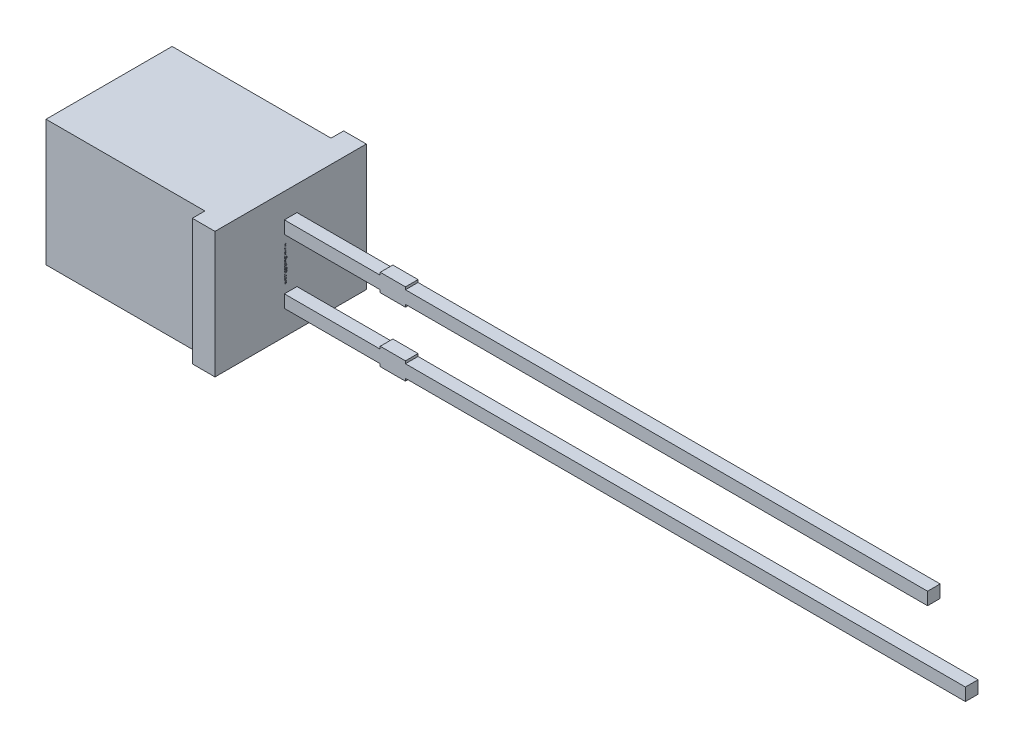
from build123d import *

# Parameters (mm, degrees)
SKETCH1_W          = 7.2
SKETCH1_H          = 5
EXTRUDE1_DEPTH     = 2.5
SKETCH1_4_W        = 3.8
SKETCH1_4_H        = 0.5
SKETCH1_4_W_2      = 1
SKETCH1_4_W_3      = 20.7
SKETCH1_4_H_2      = 0.1
SKETCH1_4_W_4      = 22.2
EXTRUDE2_DEPTH     = 0.25
EXTRUDE3_DEPTH     = 3
SKETCH2_W          = 0.026582278
SKETCH2_H          = 0.025316456
CUT_EXTRUDE1_DEPTH = 0.01


with BuildPart() as part:
    # Sketch1 → Extrude1 (new body, symmetric)
    with BuildSketch(Plane.XY):
        Rectangle(SKETCH1_W, SKETCH1_H)
    extrude(amount=EXTRUDE1_DEPTH, both=True)

    # Sketch1_4 → Extrude2 (add, symmetric)
    with BuildSketch(Plane.XY):
        with Locations((5.5, 1.27)):
            Rectangle(SKETCH1_4_W, SKETCH1_4_H)
        with Locations((7.9, 1.27)):
            Rectangle(SKETCH1_4_W_2, SKETCH1_4_H)
        with Locations((18.75, 1.27)):
            Rectangle(SKETCH1_4_W_3, SKETCH1_4_H)
        with Locations((7.9, 1.57)):
            Rectangle(SKETCH1_4_W_2, SKETCH1_4_H_2)
        with Locations((7.9, 0.97)):
            Rectangle(SKETCH1_4_W_2, SKETCH1_4_H_2)
        with Locations((7.9, -1.27)):
            Rectangle(SKETCH1_4_W_2, SKETCH1_4_H)
        with Locations((7.9, -0.97)):
            Rectangle(SKETCH1_4_W_2, SKETCH1_4_H_2)
        with Locations((19.5, -1.27)):
            Rectangle(SKETCH1_4_W_4, SKETCH1_4_H)
        with Locations((5.5, -1.27)):
            Rectangle(SKETCH1_4_W, SKETCH1_4_H)
        with Locations((7.9, -1.57)):
            Rectangle(SKETCH1_4_W_2, SKETCH1_4_H_2)
    extrude(amount=EXTRUDE2_DEPTH, both=True)

    # Sketch1_5 → Extrude3 (add, symmetric)
    with BuildSketch(Plane.XY):
        Polygon((2.7, 2.5), (2.7, -2.5), (3.6, -2.5), (3.6, -1.52), (3.6, -1.02), (3.6, 1.02), (3.6, 1.52), (3.6, 2.5), align=None)
    extrude(amount=EXTRUDE3_DEPTH, both=True)

    # Sketch2 → Cut-Extrude1 (cut)
    with BuildSketch(Plane(origin=(3.6, 0, 0), x_dir=(0, 0, -1), z_dir=(1, 0, 0))):
        Polygon((-0.175316456, 0.572151899), (-0.25, 0.595609177), (-0.25, 0.620352057), (-0.199663766, 0.636768196), (-0.25, 0.652294304), (-0.25, 0.678026108), (-0.175316456, 0.701265823), (-0.175316456, 0.676087816), (-0.226799842, 0.663093354), (-0.175316456, 0.646677215), (-0.175316456, 0.625178006), (-0.226799842, 0.608860759), (-0.175316456, 0.596044304), align=None)
        Polygon((-0.175316456, 0.437974684), (-0.25, 0.461431962), (-0.25, 0.486174842), (-0.199663766, 0.502590981), (-0.25, 0.518117089), (-0.25, 0.543848892), (-0.175316456, 0.567088608), (-0.175316456, 0.541910601), (-0.226799842, 0.528916139), (-0.175316456, 0.5125), (-0.175316456, 0.491000791), (-0.226799842, 0.474683544), (-0.175316456, 0.461867089), align=None)
        Polygon((-0.175316456, 0.303797468), (-0.25, 0.327254747), (-0.25, 0.351997627), (-0.199663766, 0.368413766), (-0.25, 0.383939873), (-0.25, 0.409671677), (-0.175316456, 0.432911392), (-0.175316456, 0.407733386), (-0.226799842, 0.394738924), (-0.175316456, 0.378322785), (-0.175316456, 0.356823576), (-0.226799842, 0.340506329), (-0.175316456, 0.327689873), align=None)
        with Locations((-0.236708861, 0.275949367)):
            Rectangle(SKETCH2_W, SKETCH2_H)
        with BuildLine():
            add(Edge.make_bspline(
                [(-0.218829114, 0.159493671), (-0.220051248, 0.159530169), (-0.22245111, 0.15960184), (-0.225958798, 0.160211426), (-0.229283102, 0.161205393), (-0.232447248, 0.162577732), (-0.235416736, 0.164371189), (-0.238219628, 0.16655446), (-0.240824172, 0.169143343), (-0.243260547, 0.172090146), (-0.245442658, 0.175387089), (-0.247348691, 0.178984804), (-0.248943362, 0.18286483), (-0.250282428, 0.187013042), (-0.251270861, 0.191459588), (-0.251994849, 0.196177087), (-0.252468166, 0.201170514), (-0.252510134, 0.204594091), (-0.252531646, 0.206348892)],
                knots=[0, 0, 0, 0, 0.907312236, 1.78165839, 2.635367075, 3.479697475, 4.336364812, 5.205276731, 6.11257575, 7.058770404, 8.040786331, 9.044147278, 10.078219212, 11.153049307, 12.278104542, 13.457648573, 14.696882856, 16, 16, 16, 16], degree=3))
            add(Edge.make_bspline(
                [(-0.252531646, 0.206348892), (-0.252507574, 0.208367148), (-0.252460949, 0.21227633), (-0.25203235, 0.217939855), (-0.251386211, 0.223207892), (-0.250419669, 0.228103607), (-0.249218904, 0.232708206), (-0.247927612, 0.237141474), (-0.246463197, 0.241422786), (-0.245363039, 0.244195876), (-0.244818038, 0.24556962)],
                knots=[0, 0, 0, 0, 1.203215828, 2.33052265, 3.384689099, 4.366106119, 5.303329643, 6.221311756, 7.118865988, 8, 8, 8, 8], degree=3))
            Line((-0.244818038, 0.24556962), (-0.220886076, 0.24556962))
            Line((-0.220886076, 0.24556962), (-0.220886076, 0.242721519))
            add(Edge.make_bspline(
                [(-0.220886076, 0.242721519), (-0.221967531, 0.241356205), (-0.224124092, 0.238633592), (-0.226886697, 0.234200359), (-0.22928886, 0.229552713), (-0.231262862, 0.224707243), (-0.232849186, 0.219810398), (-0.233942713, 0.21493502), (-0.234690062, 0.210169433), (-0.234770569, 0.207010864), (-0.234810127, 0.205458861)],
                knots=[0, 0, 0, 0, 1.030622468, 2.055194264, 3.087043286, 4.125157485, 5.149848264, 6.130935704, 7.081611712, 8, 8, 8, 8], degree=3))
            add(Edge.make_bspline(
                [(-0.234810127, 0.205458861), (-0.234809232, 0.205030082), (-0.234807317, 0.2041121), (-0.234678474, 0.202644063), (-0.234585311, 0.200985464), (-0.234376093, 0.199206598), (-0.23415751, 0.197415781), (-0.23377719, 0.195761121), (-0.233415351, 0.194257482), (-0.233047173, 0.193351), (-0.232871835, 0.192919304)],
                knots=[0, 0, 0, 0, 0.806378557, 1.726393851, 2.771014456, 3.931269413, 5.096090628, 6.161710732, 7.124547685, 8, 8, 8, 8], degree=3))
            add(Edge.make_bspline(
                [(-0.232871835, 0.192919304), (-0.232644012, 0.192439517), (-0.23219629, 0.191496634), (-0.231378683, 0.190201714), (-0.230507381, 0.189019042), (-0.229541962, 0.187957582), (-0.228364053, 0.187107314), (-0.226963197, 0.186479113), (-0.225312897, 0.186136019), (-0.224137886, 0.186096725), (-0.223516614, 0.186075949)],
                knots=[0, 0, 0, 0, 1.024407818, 2.013179384, 2.949802342, 3.859052226, 4.77034807, 5.732977883, 6.801339628, 8, 8, 8, 8], degree=3))
            add(Edge.make_bspline(
                [(-0.223516614, 0.186075949), (-0.222970718, 0.186107391), (-0.221897325, 0.186169215), (-0.220369329, 0.186751006), (-0.218947452, 0.187633905), (-0.217686737, 0.188920927), (-0.216529299, 0.190515003), (-0.215559002, 0.19247074), (-0.214678928, 0.194723719), (-0.214261659, 0.196368178), (-0.214042722, 0.197231013)],
                knots=[0, 0, 0, 0, 0.825212765, 1.622611382, 2.449701629, 3.348069183, 4.336544339, 5.428209675, 6.6506027, 8, 8, 8, 8], degree=3))
            add(Edge.make_bspline(
                [(-0.214042722, 0.197231013), (-0.213594981, 0.19919974), (-0.212677791, 0.203232648), (-0.211530684, 0.209380757), (-0.210264611, 0.215510984), (-0.20905507, 0.219469696), (-0.20846519, 0.221400316)],
                knots=[0, 0, 0, 0, 0.976104583, 1.999535498, 3.024395274, 4, 4, 4, 4], degree=3))
            add(Edge.make_bspline(
                [(-0.20846519, 0.221400316), (-0.208112197, 0.222438832), (-0.207425064, 0.224460401), (-0.206263439, 0.227351945), (-0.204993487, 0.230013057), (-0.203638356, 0.232453168), (-0.202164358, 0.23465249), (-0.200630968, 0.236647679), (-0.198977131, 0.238391205), (-0.197245211, 0.239938889), (-0.195393209, 0.241262203), (-0.193449072, 0.242416954), (-0.191388607, 0.243392589), (-0.189227318, 0.244201473), (-0.18694845, 0.244818545), (-0.184571576, 0.245239801), (-0.182088216, 0.24553819), (-0.180393863, 0.245559001), (-0.179529272, 0.24556962)],
                knots=[0, 0, 0, 0, 1.287286806, 2.505824366, 3.654938963, 4.74627059, 5.778586806, 6.75996495, 7.696030012, 8.595059759, 9.482019644, 10.363222407, 11.245851011, 12.154256429, 13.068444161, 14.012503255, 14.985824751, 16, 16, 16, 16], degree=3))
            add(Edge.make_bspline(
                [(-0.179529272, 0.24556962), (-0.178373127, 0.245532318), (-0.176097855, 0.245458909), (-0.172768811, 0.24485748), (-0.169620074, 0.24383089), (-0.166616611, 0.242444827), (-0.163803525, 0.240616199), (-0.161124978, 0.238431404), (-0.158653386, 0.235807357), (-0.156353053, 0.232830235), (-0.154273654, 0.229542851), (-0.152443098, 0.226003867), (-0.150906446, 0.222234578), (-0.149632552, 0.218249032), (-0.148677881, 0.214030563), (-0.14795895, 0.20959333), (-0.147545768, 0.204919541), (-0.147494518, 0.20172812), (-0.147468354, 0.200098892)],
                knots=[0, 0, 0, 0, 0.894990994, 1.761326291, 2.609044902, 3.454222546, 4.315366365, 5.200560057, 6.125081389, 7.100429509, 8.110379559, 9.133447974, 10.182136699, 11.259192205, 12.370181258, 13.528580438, 14.738335141, 16, 16, 16, 16], degree=3))
            add(Edge.make_bspline(
                [(-0.147468354, 0.200098892), (-0.147490546, 0.198430205), (-0.147534891, 0.19509566), (-0.147912869, 0.190114218), (-0.148468097, 0.185153716), (-0.149309803, 0.180289886), (-0.15028622, 0.175599331), (-0.151382015, 0.171186095), (-0.15261998, 0.167106634), (-0.153574325, 0.16453297), (-0.15403481, 0.163291139)],
                knots=[0, 0, 0, 0, 1.065403572, 2.129000689, 3.188532477, 4.251604565, 5.279552602, 6.247508681, 7.154397237, 8, 8, 8, 8], degree=3))
            Line((-0.15403481, 0.163291139), (-0.176582278, 0.163291139))
            Line((-0.176582278, 0.163291139), (-0.176582278, 0.166119462))
            add(Edge.make_bspline(
                [(-0.176582278, 0.166119462), (-0.175781932, 0.167192367), (-0.174145202, 0.169386485), (-0.17206153, 0.173046122), (-0.170103664, 0.177004358), (-0.168419505, 0.181283188), (-0.166960024, 0.185742216), (-0.165940858, 0.190325174), (-0.165299048, 0.194951338), (-0.165226273, 0.198053049), (-0.165189873, 0.19960443)],
                knots=[0, 0, 0, 0, 0.892283326, 1.824742884, 2.804416662, 3.836872171, 4.8899239, 5.931447339, 6.965372909, 8, 8, 8, 8], degree=3))
            add(Edge.make_bspline(
                [(-0.165189873, 0.19960443), (-0.165211326, 0.200700098), (-0.165254228, 0.202891315), (-0.165644912, 0.206159523), (-0.166275806, 0.209401584), (-0.167095088, 0.211442107), (-0.167503956, 0.212460443)],
                knots=[0, 0, 0, 0, 0.999146175, 1.998183711, 3.000980573, 4, 4, 4, 4], degree=3))
            add(Edge.make_bspline(
                [(-0.167503956, 0.212460443), (-0.167705423, 0.212893946), (-0.168108222, 0.213760664), (-0.168880786, 0.214967308), (-0.169809597, 0.216071977), (-0.170861589, 0.217064055), (-0.172017962, 0.217932452), (-0.173292788, 0.218547803), (-0.174655703, 0.218923676), (-0.175590934, 0.218965835), (-0.176068038, 0.218987342)],
                knots=[0, 0, 0, 0, 1.00524851, 2.009826503, 3.004679593, 4.035271301, 5.048246368, 6.034938417, 6.997532266, 8, 8, 8, 8], degree=3))
            add(Edge.make_bspline(
                [(-0.176068038, 0.218987342), (-0.176706203, 0.218952904), (-0.177925679, 0.218887095), (-0.179641475, 0.218280511), (-0.181119909, 0.217295678), (-0.182114829, 0.216135073), (-0.182812267, 0.215017943), (-0.183322777, 0.213982284), (-0.183806136, 0.212773057), (-0.184303605, 0.211401809), (-0.184794792, 0.209865482), (-0.185270339, 0.208156925), (-0.185719635, 0.206274208), (-0.186005825, 0.204958333), (-0.186155063, 0.204272152)],
                knots=[0, 0, 0, 0, 1.173816843, 2.243057204, 3.312297565, 4.415174738, 5.03266065, 5.73970059, 6.541434878, 7.433956553, 8.430083051, 9.515931566, 10.70464786, 12, 12, 12, 12], degree=3))
            add(Edge.make_bspline(
                [(-0.186155063, 0.204272152), (-0.186531125, 0.202439363), (-0.187270003, 0.198838337), (-0.188373491, 0.193437153), (-0.18964846, 0.18793438), (-0.190797263, 0.184269053), (-0.191396361, 0.182357595)],
                knots=[0, 0, 0, 0, 0.995744513, 1.956417928, 2.934277412, 4, 4, 4, 4], degree=3))
            add(Edge.make_bspline(
                [(-0.191396361, 0.182357595), (-0.191715605, 0.181411041), (-0.192340097, 0.179559428), (-0.19342638, 0.176918797), (-0.194600363, 0.174471738), (-0.195841894, 0.172204706), (-0.19718586, 0.170130736), (-0.198608507, 0.168236053), (-0.200135416, 0.166552235), (-0.201748644, 0.16505467), (-0.203458744, 0.16373551), (-0.205297817, 0.162603212), (-0.207246619, 0.161630984), (-0.209332819, 0.160861379), (-0.211527406, 0.160243358), (-0.213858774, 0.159820261), (-0.21630315, 0.159526278), (-0.217977728, 0.159504661), (-0.218829114, 0.159493671)],
                knots=[0, 0, 0, 0, 1.237467875, 2.420686895, 3.535046182, 4.599015201, 5.620884487, 6.594603852, 7.531477383, 8.433220087, 9.318759595, 10.202828513, 11.105163009, 12.01247538, 12.953896178, 13.926381251, 14.945733412, 16, 16, 16, 16], degree=3))
        make_face()
        with BuildLine():
            Line((-0.25, 0.067088608), (-0.25, 0.091139241))
            Line((-0.25, 0.091139241), (-0.242167722, 0.091139241))
            add(Edge.make_bspline(
                [(-0.242167722, 0.091139241), (-0.24297628, 0.092232549), (-0.244535168, 0.094340433), (-0.246615386, 0.097513458), (-0.248390652, 0.100539548), (-0.249949873, 0.103453039), (-0.251125258, 0.106475242), (-0.251953324, 0.109706756), (-0.252453097, 0.113209581), (-0.252504881, 0.115636475), (-0.252531646, 0.116890823)],
                knots=[0, 0, 0, 0, 1.150872466, 2.218865267, 3.209461834, 4.120482262, 5.012764827, 5.946708227, 6.938749913, 8, 8, 8, 8], degree=3))
            add(Edge.make_bspline(
                [(-0.252531646, 0.116890823), (-0.252508927, 0.117907175), (-0.252464686, 0.119886305), (-0.252119808, 0.122763545), (-0.251582157, 0.125471173), (-0.250774566, 0.127986213), (-0.249808763, 0.130350202), (-0.248528805, 0.132487752), (-0.247098631, 0.134491354), (-0.245391585, 0.136273026), (-0.243493852, 0.137888648), (-0.241361392, 0.139271198), (-0.239028466, 0.140448909), (-0.236476612, 0.141390006), (-0.233718309, 0.142145096), (-0.230739061, 0.142669028), (-0.227551934, 0.142989621), (-0.225356803, 0.14302156), (-0.224228639, 0.143037975)],
                knots=[0, 0, 0, 0, 1.109008058, 2.159558935, 3.158726032, 4.116861086, 5.039058877, 5.938775559, 6.82970133, 7.720510853, 8.624361809, 9.544451588, 10.487360536, 11.471068125, 12.508000841, 13.604731202, 14.768976642, 16, 16, 16, 16], degree=3))
            Line((-0.224228639, 0.143037975), (-0.175316456, 0.143037975))
            Line((-0.175316456, 0.143037975), (-0.175316456, 0.118987342))
            Line((-0.175316456, 0.118987342), (-0.21289557, 0.118987342))
            add(Edge.make_bspline(
                [(-0.21289557, 0.118987342), (-0.213812041, 0.118985706), (-0.215566256, 0.118982576), (-0.218072063, 0.118900237), (-0.220340235, 0.118779336), (-0.222382264, 0.118640631), (-0.224229015, 0.118387615), (-0.225895176, 0.118009906), (-0.227414778, 0.11753908), (-0.228321479, 0.117074761), (-0.228757911, 0.116851266)],
                knots=[0, 0, 0, 0, 1.361401701, 2.605856924, 3.723918663, 4.735739235, 5.645738665, 6.489217889, 7.27279937, 8, 8, 8, 8], degree=3))
            add(Edge.make_bspline(
                [(-0.228757911, 0.116851266), (-0.229156626, 0.116621259), (-0.229940466, 0.116169086), (-0.230946644, 0.115248796), (-0.231790911, 0.114170053), (-0.23244694, 0.112892449), (-0.232945889, 0.111405901), (-0.233286125, 0.109677971), (-0.233501627, 0.107692609), (-0.233529535, 0.106283591), (-0.233544304, 0.105537975)],
                knots=[0, 0, 0, 0, 0.849138082, 1.669332372, 2.503455908, 3.370611167, 4.311442699, 5.394692208, 6.621337967, 8, 8, 8, 8], degree=3))
            add(Edge.make_bspline(
                [(-0.233544304, 0.105537975), (-0.233526947, 0.104996691), (-0.233491259, 0.103883773), (-0.233258814, 0.102172461), (-0.232902139, 0.100375884), (-0.232242283, 0.097861301), (-0.231056104, 0.094694674), (-0.229701697, 0.092335372), (-0.229015032, 0.091139241)],
                knots=[0, 0, 0, 0, 0.638127216, 1.312033637, 2.033062677, 2.79661882, 4.375931797, 6, 6, 6, 6], degree=3))
            Line((-0.229015032, 0.091139241), (-0.175316456, 0.091139241))
            Line((-0.175316456, 0.091139241), (-0.175316456, 0.067088608))
            Line((-0.175316456, 0.067088608), (-0.25, 0.067088608))
        make_face()
        with BuildLine():
            Line((-0.25, -0.030379747), (-0.25, -0.006329114))
            Line((-0.25, -0.006329114), (-0.212420886, -0.006329114))
            add(Edge.make_bspline(
                [(-0.212420886, -0.006329114), (-0.210890843, -0.0063046), (-0.207839818, -0.006255716), (-0.204077407, -0.005973592), (-0.201235083, -0.00559507), (-0.199397202, -0.005225415), (-0.197849063, -0.004793715), (-0.196963303, -0.004381435), (-0.196558544, -0.004193038)],
                knots=[0, 0, 0, 0, 1.709124929, 3.408128882, 4.211124727, 4.91016634, 5.501986363, 6, 6, 6, 6], degree=3))
            add(Edge.make_bspline(
                [(-0.196558544, -0.004193038), (-0.196160491, -0.003948575), (-0.195380051, -0.003469272), (-0.194367038, -0.002531948), (-0.193538197, -0.001438061), (-0.192856647, -0.000167292), (-0.192386066, 0.001323905), (-0.191992836, 0.003040645), (-0.191825927, 0.005027263), (-0.191790767, 0.006434533), (-0.191772152, 0.007179589)],
                knots=[0, 0, 0, 0, 0.86006424, 1.686277094, 2.52783008, 3.38194165, 4.331801563, 5.402842185, 6.624978739, 8, 8, 8, 8], degree=3))
            add(Edge.make_bspline(
                [(-0.191772152, 0.007179589), (-0.191828889, 0.00831141), (-0.191944743, 0.010622505), (-0.19265625, 0.013484698), (-0.193475209, 0.015815302), (-0.19423404, 0.017667827), (-0.195205482, 0.019576457), (-0.195927304, 0.020855869), (-0.196301424, 0.021518987)],
                knots=[0, 0, 0, 0, 1.338371478, 2.732853438, 3.468019217, 4.261884641, 5.099136535, 6, 6, 6, 6], degree=3))
            Line((-0.196301424, 0.021518987), (-0.25, 0.021518987))
            Line((-0.25, 0.021518987), (-0.25, 0.04556962))
            Line((-0.25, 0.04556962), (-0.175316456, 0.04556962))
            Line((-0.175316456, 0.04556962), (-0.175316456, 0.021518987))
            Line((-0.175316456, 0.021518987), (-0.183148734, 0.021518987))
            add(Edge.make_bspline(
                [(-0.183148734, 0.021518987), (-0.182342583, 0.020461581), (-0.18077336, 0.018403276), (-0.17873294, 0.015224038), (-0.176934171, 0.01214014), (-0.175421354, 0.009087131), (-0.174214579, 0.005972176), (-0.17340359, 0.002709417), (-0.172859787, -0.000706989), (-0.172810094, -0.003043704), (-0.17278481, -0.004232595)],
                knots=[0, 0, 0, 0, 1.126119141, 2.192057864, 3.198061997, 4.149848529, 5.076251285, 6.021887753, 6.99356175, 8, 8, 8, 8], degree=3))
            add(Edge.make_bspline(
                [(-0.17278481, -0.004232595), (-0.172810199, -0.005228866), (-0.172859763, -0.007173765), (-0.173169473, -0.010008526), (-0.173720137, -0.012679947), (-0.174517966, -0.015172221), (-0.175503578, -0.017514841), (-0.176735093, -0.019676785), (-0.178193516, -0.021668856), (-0.179854519, -0.023497257), (-0.181744245, -0.025128075), (-0.18386151, -0.026545111), (-0.186204606, -0.027725092), (-0.188764915, -0.028695805), (-0.191530024, -0.029470228), (-0.19452599, -0.029985359), (-0.197730169, -0.030339143), (-0.199946212, -0.030365941), (-0.201087816, -0.030379747)],
                knots=[0, 0, 0, 0, 1.08848837, 2.124922927, 3.110950502, 4.063144162, 4.979605775, 5.882838355, 6.774625441, 7.671951181, 8.57587277, 9.494821853, 10.448322275, 11.435533005, 12.482327682, 13.580118324, 14.753386918, 16, 16, 16, 16], degree=3))
            Line((-0.201087816, -0.030379747), (-0.25, -0.030379747))
        make_face()
        Polygon((-0.25, -0.125316456), (-0.25, -0.053164557), (-0.15, -0.053164557), (-0.15, -0.078481013), (-0.231012658, -0.078481013), (-0.231012658, -0.125316456), align=None)
        Polygon((-0.25, -0.212658228), (-0.25, -0.140506329), (-0.15, -0.140506329), (-0.15, -0.212658228), (-0.168987342, -0.212658228), (-0.168987342, -0.165822785), (-0.186708861, -0.165822785), (-0.186708861, -0.208860759), (-0.205696203, -0.208860759), (-0.205696203, -0.165822785), (-0.231012658, -0.165822785), (-0.231012658, -0.212658228), align=None)
        with BuildLine():
            add(Edge.make_bspline(
                [(-0.200098892, -0.329113924), (-0.201246581, -0.329094609), (-0.203519467, -0.329056357), (-0.206884274, -0.328761165), (-0.210149949, -0.32823514), (-0.213334198, -0.327555959), (-0.216413126, -0.326633453), (-0.219420703, -0.325551739), (-0.222326196, -0.324242093), (-0.225127631, -0.322737241), (-0.227799734, -0.321087768), (-0.230319942, -0.319313019), (-0.23270316, -0.31746724), (-0.234898054, -0.315477927), (-0.236940074, -0.313398746), (-0.238830888, -0.311223217), (-0.240534319, -0.308918153), (-0.241557203, -0.30731099), (-0.242068829, -0.30650712)],
                knots=[0, 0, 0, 0, 1.105570398, 2.18947457, 3.250358341, 4.290584537, 5.323553275, 6.344225964, 7.367641686, 8.3905646, 9.405808457, 10.390761353, 11.358902336, 12.307789878, 13.241960776, 14.165076779, 15.082208636, 16, 16, 16, 16], degree=3))
            add(Edge.make_bspline(
                [(-0.242068829, -0.30650712), (-0.242780968, -0.305267892), (-0.244208881, -0.302783112), (-0.245877472, -0.298799278), (-0.247281588, -0.294673795), (-0.248336012, -0.290323409), (-0.249063056, -0.285676399), (-0.249623862, -0.28067499), (-0.249925622, -0.275267401), (-0.249974642, -0.271532506), (-0.25, -0.269600475)],
                knots=[0, 0, 0, 0, 0.896288622, 1.797150563, 2.705281913, 3.629615989, 4.602417572, 5.655716007, 6.787320449, 8, 8, 8, 8], degree=3))
            Line((-0.25, -0.269600475), (-0.25, -0.234177215))
            Line((-0.25, -0.234177215), (-0.15, -0.234177215))
            Line((-0.15, -0.234177215), (-0.15, -0.270609177))
            add(Edge.make_bspline(
                [(-0.15, -0.270609177), (-0.150016611, -0.272587909), (-0.150048652, -0.276404637), (-0.150466242, -0.281921476), (-0.151063066, -0.287026684), (-0.151987937, -0.291712032), (-0.153103282, -0.296012037), (-0.154462411, -0.299937513), (-0.155961118, -0.303549287), (-0.157234811, -0.305728129), (-0.157852057, -0.306784019)],
                knots=[0, 0, 0, 0, 1.267175336, 2.444223962, 3.542125549, 4.557526608, 5.500936977, 6.385043188, 7.217374394, 8, 8, 8, 8], degree=3))
            add(Edge.make_bspline(
                [(-0.157852057, -0.306784019), (-0.158388598, -0.307634972), (-0.159455511, -0.309327097), (-0.161237363, -0.311728312), (-0.16319344, -0.313957739), (-0.165245259, -0.316086242), (-0.167448146, -0.318066059), (-0.169786853, -0.319909259), (-0.172264947, -0.321613076), (-0.174874416, -0.323171039), (-0.177604468, -0.324591854), (-0.180477527, -0.32578116), (-0.183456057, -0.326830509), (-0.186565019, -0.327636046), (-0.189772856, -0.32833396), (-0.1931142, -0.328768694), (-0.196566688, -0.329055305), (-0.198911578, -0.32909422), (-0.200098892, -0.329113924)],
                knots=[0, 0, 0, 0, 0.964065863, 1.917049184, 2.86229036, 3.805247319, 4.749389377, 5.698846072, 6.657678277, 7.629829384, 8.610569287, 9.604676042, 10.607940105, 11.6349849, 12.681042988, 13.752616828, 14.862056989, 16, 16, 16, 16], degree=3))
        make_face()
        with BuildLine():
            add(Edge.make_bspline(
                [(-0.199940665, -0.302531646), (-0.199135905, -0.302521405), (-0.197557321, -0.302501317), (-0.195241806, -0.30230975), (-0.193012156, -0.302050694), (-0.190877464, -0.30161964), (-0.188817893, -0.301119993), (-0.186860399, -0.300477843), (-0.184980826, -0.299753447), (-0.183203337, -0.298871809), (-0.181494955, -0.297898172), (-0.17990944, -0.296750679), (-0.178396553, -0.295502341), (-0.176968569, -0.294124054), (-0.175662673, -0.292581114), (-0.174432597, -0.290921012), (-0.173304271, -0.289120654), (-0.172644221, -0.287847665), (-0.172310127, -0.287203323)],
                knots=[0, 0, 0, 0, 1.152093354, 2.259898929, 3.325467225, 4.364140538, 5.376172865, 6.358396836, 7.312077728, 8.257828931, 9.196960457, 10.124297759, 11.056236784, 12.004246951, 12.961658638, 13.947279359, 14.960983522, 16, 16, 16, 16], degree=3))
            add(Edge.make_bspline(
                [(-0.172310127, -0.287203323), (-0.172003415, -0.286528425), (-0.17139549, -0.285190731), (-0.170664298, -0.283119908), (-0.170091462, -0.281030524), (-0.169660604, -0.278828925), (-0.169338673, -0.276359165), (-0.169141415, -0.273433583), (-0.168999245, -0.269977674), (-0.168991494, -0.267490959), (-0.168987342, -0.266159019)],
                knots=[0, 0, 0, 0, 0.826967603, 1.639107464, 2.447640171, 3.242670507, 4.14065217, 5.225198036, 6.513753944, 8, 8, 8, 8], degree=3))
            Line((-0.168987342, -0.266159019), (-0.168987342, -0.259493671))
            Line((-0.168987342, -0.259493671), (-0.231012658, -0.259493671))
            Line((-0.231012658, -0.259493671), (-0.231012658, -0.266159019))
            add(Edge.make_bspline(
                [(-0.231012658, -0.266159019), (-0.231007909, -0.266917226), (-0.230998739, -0.268380991), (-0.230955677, -0.270497235), (-0.230908789, -0.272463031), (-0.230792327, -0.274267902), (-0.230719681, -0.275926587), (-0.230541302, -0.277413368), (-0.230399122, -0.278755857), (-0.230131399, -0.280323454), (-0.229715216, -0.28217662), (-0.229037037, -0.28433788), (-0.228186642, -0.286478414), (-0.227501675, -0.287866987), (-0.227155854, -0.288568038)],
                knots=[0, 0, 0, 0, 1.186793418, 2.291178421, 3.313283093, 4.264083014, 5.122158624, 5.910777728, 6.607099052, 7.234812932, 8.398911528, 9.577194775, 10.776795607, 12, 12, 12, 12], degree=3))
            add(Edge.make_bspline(
                [(-0.227155854, -0.288568038), (-0.226814338, -0.289153154), (-0.226140824, -0.29030708), (-0.22500675, -0.291930584), (-0.223799025, -0.293438302), (-0.222510574, -0.294834314), (-0.221122333, -0.296097614), (-0.219655791, -0.297249633), (-0.218107813, -0.298280082), (-0.215914295, -0.299515471), (-0.212883358, -0.300738716), (-0.208915972, -0.301778259), (-0.204556209, -0.30241513), (-0.201518591, -0.302491812), (-0.199940665, -0.302531646)],
                knots=[0, 0, 0, 0, 0.755160452, 1.489275589, 2.205657296, 2.907868421, 3.605098304, 4.296256403, 4.985378686, 5.676536785, 7.100390329, 8.614249252, 10.241231541, 12, 12, 12, 12], degree=3))
        make_face(mode=Mode.SUBTRACT)
        with Locations((-0.236708861, -0.360759494)):
            Rectangle(SKETCH2_W, SKETCH2_H)
        with BuildLine():
            add(Edge.make_bspline(
                [(-0.252531646, -0.435403481), (-0.252509834, -0.433813368), (-0.252467023, -0.430692232), (-0.251990106, -0.42612089), (-0.25127241, -0.421755717), (-0.250251504, -0.417609409), (-0.248904008, -0.413695618), (-0.247251072, -0.41003198), (-0.245265888, -0.406625123), (-0.243686679, -0.404566476), (-0.242899525, -0.403540348)],
                knots=[0, 0, 0, 0, 1.123670284, 2.205584497, 3.245308791, 4.249063313, 5.220352711, 6.167273909, 7.086481357, 8, 8, 8, 8], degree=3))
            add(Edge.make_bspline(
                [(-0.242899525, -0.403540348), (-0.242044751, -0.402588601), (-0.240338508, -0.400688786), (-0.237367081, -0.398222853), (-0.234084037, -0.396099767), (-0.230481815, -0.394314215), (-0.226565086, -0.392883291), (-0.222320424, -0.391860157), (-0.217759643, -0.391240912), (-0.21461171, -0.391173746), (-0.212994462, -0.391139241)],
                knots=[0, 0, 0, 0, 0.916457077, 1.82937027, 2.759194969, 3.714948755, 4.706655623, 5.743329475, 6.840637961, 8, 8, 8, 8], degree=3))
            add(Edge.make_bspline(
                [(-0.212994462, -0.391139241), (-0.211291235, -0.391178001), (-0.207990155, -0.391253124), (-0.203217967, -0.391916883), (-0.198800287, -0.392986496), (-0.194748378, -0.394524054), (-0.191055187, -0.396454496), (-0.187683352, -0.398718989), (-0.184640428, -0.401339514), (-0.182894988, -0.403346653), (-0.182021361, -0.404351266)],
                knots=[0, 0, 0, 0, 1.171797512, 2.271099083, 3.308930235, 4.294129479, 5.24602549, 6.17106565, 7.084581485, 8, 8, 8, 8], degree=3))
            add(Edge.make_bspline(
                [(-0.182021361, -0.404351266), (-0.181252774, -0.405377136), (-0.179706318, -0.407441268), (-0.177805619, -0.410844773), (-0.176210833, -0.414467988), (-0.174963188, -0.418297559), (-0.174009283, -0.422270367), (-0.173285439, -0.426330027), (-0.172864881, -0.43047628), (-0.172811629, -0.43326648), (-0.17278481, -0.434671677)],
                knots=[0, 0, 0, 0, 0.952130878, 1.915761808, 2.890227217, 3.891541892, 4.905612075, 5.925811839, 6.955400088, 8, 8, 8, 8], degree=3))
            add(Edge.make_bspline(
                [(-0.17278481, -0.434671677), (-0.172801812, -0.435918396), (-0.172835245, -0.438369867), (-0.173157354, -0.441970914), (-0.173690473, -0.445425455), (-0.174429076, -0.448730387), (-0.175320679, -0.451904334), (-0.17635982, -0.454954511), (-0.177493088, -0.457914321), (-0.178377623, -0.45981489), (-0.178817247, -0.460759494)],
                knots=[0, 0, 0, 0, 1.107648782, 2.178012834, 3.209595929, 4.211695017, 5.185427128, 6.137685403, 7.07440854, 8, 8, 8, 8], degree=3))
            Line((-0.178817247, -0.460759494), (-0.199367089, -0.460759494))
            Line((-0.199367089, -0.460759494), (-0.199367089, -0.45741693))
            add(Edge.make_bspline(
                [(-0.199367089, -0.45741693), (-0.198949869, -0.456917386), (-0.198048154, -0.45583775), (-0.196627402, -0.454051335), (-0.195097809, -0.451902393), (-0.194205863, -0.450248857), (-0.193730222, -0.449367089)],
                knots=[0, 0, 0, 0, 0.792826818, 1.713491785, 2.780691913, 4, 4, 4, 4], degree=3))
            add(Edge.make_bspline(
                [(-0.193730222, -0.449367089), (-0.193288264, -0.448439154), (-0.192382404, -0.446537209), (-0.19154957, -0.443981204), (-0.190981844, -0.441789202), (-0.190725422, -0.439971666), (-0.190535861, -0.438038046), (-0.190516354, -0.436702803), (-0.190506329, -0.436016614)],
                knots=[0, 0, 0, 0, 1.332524827, 2.731214173, 3.480270227, 4.267952375, 5.109889624, 6, 6, 6, 6], degree=3))
            add(Edge.make_bspline(
                [(-0.190506329, -0.436016614), (-0.190525879, -0.435251058), (-0.190563765, -0.433767448), (-0.190840821, -0.431605939), (-0.191319079, -0.429587528), (-0.191959179, -0.427684306), (-0.192846792, -0.425946243), (-0.193880429, -0.424319403), (-0.195106231, -0.422827143), (-0.196547173, -0.421507882), (-0.198127102, -0.420315156), (-0.199861217, -0.419295954), (-0.201707816, -0.418383498), (-0.203712265, -0.41768856), (-0.205841041, -0.417128822), (-0.208104161, -0.416739892), (-0.210503671, -0.416497934), (-0.212149979, -0.416470016), (-0.212994462, -0.416455696)],
                knots=[0, 0, 0, 0, 1.087302107, 2.107140881, 3.088415001, 4.030197574, 4.951552271, 5.852940509, 6.764198256, 7.685219758, 8.621679636, 9.570836121, 10.538340132, 11.542450476, 12.578202196, 13.66207107, 14.800746211, 16, 16, 16, 16], degree=3))
            add(Edge.make_bspline(
                [(-0.212994462, -0.416455696), (-0.213858618, -0.416470471), (-0.215537631, -0.416499177), (-0.217979242, -0.416732691), (-0.220260673, -0.417148582), (-0.222385993, -0.41771983), (-0.224352011, -0.418444178), (-0.226149408, -0.419349295), (-0.227806215, -0.420385652), (-0.229268827, -0.42163021), (-0.230585149, -0.422994093), (-0.231721283, -0.424508985), (-0.232669428, -0.426168224), (-0.233473891, -0.427950405), (-0.234052289, -0.429883445), (-0.234488981, -0.431939982), (-0.234777538, -0.434129537), (-0.234799101, -0.435639891), (-0.234810127, -0.436412184)],
                knots=[0, 0, 0, 0, 1.230336593, 2.390482092, 3.487897344, 4.52859895, 5.520747884, 6.465347575, 7.38981449, 8.296085817, 9.192433006, 10.084246191, 10.984321635, 11.908883871, 12.862027947, 13.850751296, 14.901019963, 16, 16, 16, 16], degree=3))
            add(Edge.make_bspline(
                [(-0.234810127, -0.436412184), (-0.234801999, -0.437138038), (-0.234786155, -0.438553063), (-0.234568078, -0.44061781), (-0.234292195, -0.442578718), (-0.233852787, -0.444414258), (-0.233310412, -0.446109524), (-0.232743906, -0.447669947), (-0.232139122, -0.449082395), (-0.231671567, -0.449943749), (-0.231447785, -0.450356013)],
                knots=[0, 0, 0, 0, 1.200823684, 2.340960236, 3.433630075, 4.476504061, 5.46014544, 6.378484521, 7.223905657, 8, 8, 8, 8], degree=3))
            add(Edge.make_bspline(
                [(-0.231447785, -0.450356013), (-0.23101789, -0.451056218), (-0.230186248, -0.452410785), (-0.228784682, -0.454249513), (-0.227370422, -0.455894382), (-0.226414205, -0.456918894), (-0.225949367, -0.45741693)],
                knots=[0, 0, 0, 0, 1.098601379, 2.125273733, 3.088655601, 4, 4, 4, 4], degree=3))
            Line((-0.225949367, -0.45741693), (-0.225949367, -0.460759494))
            Line((-0.225949367, -0.460759494), (-0.246657437, -0.460759494))
            add(Edge.make_bspline(
                [(-0.246657437, -0.460759494), (-0.247094931, -0.459814104), (-0.247970024, -0.457923097), (-0.249123896, -0.455008518), (-0.250092057, -0.452020545), (-0.250995137, -0.448972172), (-0.251683499, -0.445800089), (-0.252176622, -0.442477058), (-0.252477534, -0.43899556), (-0.252513362, -0.436617171), (-0.252531646, -0.435403481)],
                knots=[0, 0, 0, 0, 0.952012952, 1.904254716, 2.862729541, 3.822037426, 4.808956931, 5.82647221, 6.890850784, 8, 8, 8, 8], degree=3))
        make_face()
        with BuildLine():
            add(Edge.make_bspline(
                [(-0.212697785, -0.553164557), (-0.214202691, -0.553139862), (-0.217136157, -0.553091723), (-0.221407948, -0.552552407), (-0.225443946, -0.551739627), (-0.229231154, -0.550567096), (-0.232788429, -0.549086703), (-0.236078221, -0.547235764), (-0.239131451, -0.545064759), (-0.241921336, -0.542573722), (-0.244419846, -0.53977252), (-0.246615099, -0.536698338), (-0.248428541, -0.533324511), (-0.249940631, -0.5297102), (-0.251109866, -0.525825548), (-0.251922584, -0.521671329), (-0.252458054, -0.517254195), (-0.252506706, -0.514215776), (-0.252531646, -0.512658228)],
                knots=[0, 0, 0, 0, 1.120167703, 2.183507516, 3.201345984, 4.182878364, 5.131270247, 6.065524964, 6.98789854, 7.91635504, 8.84481154, 9.778033504, 10.722808862, 11.691211189, 12.691525459, 13.738229926, 14.840575679, 16, 16, 16, 16], degree=3))
            add(Edge.make_bspline(
                [(-0.252531646, -0.512658228), (-0.252506624, -0.511100707), (-0.252457811, -0.508062341), (-0.25192348, -0.503644832), (-0.251105529, -0.499485737), (-0.249949428, -0.49559643), (-0.248422879, -0.491987684), (-0.246615831, -0.488617817), (-0.244419638, -0.485544052), (-0.241921446, -0.482742566), (-0.239131219, -0.480252248), (-0.236079037, -0.478078657), (-0.232783083, -0.476236243), (-0.229240037, -0.474718389), (-0.225439199, -0.473585065), (-0.221408758, -0.472761602), (-0.217135938, -0.472225394), (-0.214202617, -0.472176819), (-0.212697785, -0.472151899)],
                knots=[0, 0, 0, 0, 1.15937715, 2.261678054, 3.308339936, 4.313313916, 5.277148057, 6.221884977, 7.155068972, 8.083487698, 9.011906424, 9.934242473, 10.868459181, 11.818729666, 12.798784262, 13.81658132, 14.879877871, 16, 16, 16, 16], degree=3))
            add(Edge.make_bspline(
                [(-0.212697785, -0.472151899), (-0.211186361, -0.472177022), (-0.208233351, -0.472226107), (-0.203934478, -0.472761477), (-0.199873828, -0.473579494), (-0.196065514, -0.474739526), (-0.192513914, -0.476255799), (-0.18921181, -0.478096824), (-0.186165235, -0.480293292), (-0.183375483, -0.48280279), (-0.180879102, -0.485614584), (-0.178706197, -0.488708516), (-0.176869539, -0.492060435), (-0.175347706, -0.495667634), (-0.174213141, -0.49955419), (-0.173395562, -0.503691132), (-0.17285749, -0.508088526), (-0.172809478, -0.511107264), (-0.17278481, -0.512658228)],
                knots=[0, 0, 0, 0, 1.124034801, 2.196132384, 3.217834281, 4.203147447, 5.152578239, 6.085969439, 7.010345409, 7.941219594, 8.872481455, 9.802010446, 10.748267785, 11.711250247, 12.709230373, 13.754967386, 14.846549946, 16, 16, 16, 16], degree=3))
            add(Edge.make_bspline(
                [(-0.17278481, -0.512658228), (-0.172809532, -0.514228966), (-0.172857665, -0.51728713), (-0.173393868, -0.521730542), (-0.174206873, -0.525904381), (-0.175373269, -0.529803006), (-0.176884682, -0.533428756), (-0.17871934, -0.536788831), (-0.180921398, -0.539860139), (-0.183428554, -0.542647393), (-0.186233956, -0.545127634), (-0.189283579, -0.54729655), (-0.192603295, -0.549103768), (-0.196158163, -0.550585538), (-0.199951933, -0.551757711), (-0.203986038, -0.552578696), (-0.208261035, -0.553084687), (-0.211193165, -0.553137471), (-0.212697785, -0.553164557)],
                knots=[0, 0, 0, 0, 1.167358552, 2.272800965, 3.322628764, 4.326027541, 5.29287265, 6.238482395, 7.166210353, 8.096447471, 9.020151799, 9.945039072, 10.873038967, 11.824425184, 12.804379233, 13.820580988, 14.881633558, 16, 16, 16, 16], degree=3))
        make_face()
        with BuildLine():
            add(Edge.make_bspline(
                [(-0.231190665, -0.523457278), (-0.230690658, -0.523812456), (-0.229673086, -0.524535285), (-0.227972663, -0.525405537), (-0.226150868, -0.526193542), (-0.224121587, -0.526811737), (-0.221819141, -0.527291059), (-0.219165549, -0.52760245), (-0.216130036, -0.527832094), (-0.213977323, -0.527842556), (-0.212836234, -0.527848101)],
                knots=[0, 0, 0, 0, 0.764956307, 1.556776596, 2.379454426, 3.241401993, 4.200532455, 5.312591107, 6.575484591, 8, 8, 8, 8], degree=3))
            add(Edge.make_bspline(
                [(-0.212836234, -0.527848101), (-0.211761353, -0.527830412), (-0.209701996, -0.527796522), (-0.206742233, -0.527610152), (-0.204058807, -0.527261478), (-0.201641411, -0.5267636), (-0.199470723, -0.526153829), (-0.19752836, -0.525427894), (-0.195809758, -0.524589376), (-0.194804527, -0.523903909), (-0.194323576, -0.523575949)],
                knots=[0, 0, 0, 0, 1.337076348, 2.561692668, 3.686680134, 4.69989255, 5.629188848, 6.488203485, 7.276684665, 8, 8, 8, 8], degree=3))
            add(Edge.make_bspline(
                [(-0.194323576, -0.523575949), (-0.193884293, -0.523238652), (-0.193022537, -0.522576962), (-0.191940352, -0.521400911), (-0.191042058, -0.520136352), (-0.190382017, -0.51875605), (-0.189862759, -0.517310883), (-0.189515923, -0.515802557), (-0.189287802, -0.514247405), (-0.189256424, -0.513193069), (-0.189240506, -0.512658228)],
                knots=[0, 0, 0, 0, 1.058684453, 2.076859345, 3.046867319, 4.017860406, 4.996047344, 5.981941452, 6.976284511, 8, 8, 8, 8], degree=3))
            add(Edge.make_bspline(
                [(-0.189240506, -0.512658228), (-0.189251453, -0.512130296), (-0.189272863, -0.511097679), (-0.189452545, -0.509595013), (-0.189747135, -0.508184065), (-0.190165068, -0.506844191), (-0.190760551, -0.505552217), (-0.191616975, -0.504317872), (-0.192692306, -0.503101936), (-0.193542825, -0.502363688), (-0.193987342, -0.501977848)],
                knots=[0, 0, 0, 0, 1.041978199, 2.038073998, 2.982578265, 3.884042198, 4.804014415, 5.778706634, 6.839057036, 8, 8, 8, 8], degree=3))
            add(Edge.make_bspline(
                [(-0.193987342, -0.501977848), (-0.194461968, -0.501644363), (-0.195460568, -0.500942719), (-0.197165089, -0.500059744), (-0.199127009, -0.49932839), (-0.20131075, -0.49863615), (-0.203781898, -0.498117886), (-0.206535176, -0.497717147), (-0.209589603, -0.497516433), (-0.21172182, -0.497484858), (-0.212836234, -0.497468354)],
                knots=[0, 0, 0, 0, 0.706185926, 1.485796665, 2.33004681, 3.254820698, 4.274138656, 5.402098861, 6.642194297, 8, 8, 8, 8], degree=3))
            add(Edge.make_bspline(
                [(-0.212836234, -0.497468354), (-0.213838698, -0.497477501), (-0.21577981, -0.497495212), (-0.218586195, -0.497694126), (-0.221190128, -0.498022802), (-0.22358016, -0.498499446), (-0.225765057, -0.49907369), (-0.227716716, -0.499821164), (-0.229471774, -0.500644638), (-0.230499515, -0.501344976), (-0.23099288, -0.501681171)],
                knots=[0, 0, 0, 0, 1.270915159, 2.460926195, 3.565223763, 4.596447547, 5.549594966, 6.425286377, 7.244063354, 8, 8, 8, 8], degree=3))
            add(Edge.make_bspline(
                [(-0.23099288, -0.501681171), (-0.231409366, -0.502021731), (-0.232230494, -0.502693168), (-0.233314509, -0.503842086), (-0.23417586, -0.505125798), (-0.234906348, -0.506477001), (-0.235435594, -0.507938804), (-0.235812201, -0.509490696), (-0.236027955, -0.511142431), (-0.236059682, -0.512275225), (-0.236075949, -0.512856013)],
                knots=[0, 0, 0, 0, 1.011121112, 1.993489184, 2.956264801, 3.910060304, 4.874908638, 5.87009835, 6.907993364, 8, 8, 8, 8], degree=3))
            add(Edge.make_bspline(
                [(-0.236075949, -0.512856013), (-0.236022367, -0.513856962), (-0.235915445, -0.515854325), (-0.235203793, -0.518269474), (-0.234354513, -0.520076797), (-0.233475258, -0.521316068), (-0.232435719, -0.522472259), (-0.231609742, -0.523125727), (-0.231190665, -0.523457278)],
                knots=[0, 0, 0, 0, 1.48399549, 2.96126462, 3.700919455, 4.439278468, 5.208134679, 6, 6, 6, 6], degree=3))
        make_face(mode=Mode.SUBTRACT)
        with BuildLine():
            Line((-0.196301424, -0.644303797), (-0.25, -0.644303797))
            Line((-0.25, -0.644303797), (-0.25, -0.620253165))
            Line((-0.25, -0.620253165), (-0.212143987, -0.620253165))
            add(Edge.make_bspline(
                [(-0.212143987, -0.620253165), (-0.211253953, -0.620247698), (-0.209546322, -0.62023721), (-0.207086708, -0.620204186), (-0.204838103, -0.620123915), (-0.202791904, -0.620016376), (-0.200932439, -0.619829431), (-0.199257604, -0.619518092), (-0.197752078, -0.619096595), (-0.19685113, -0.618688245), (-0.196420095, -0.61849288)],
                knots=[0, 0, 0, 0, 1.339742217, 2.570446543, 3.702449567, 4.726327994, 5.654556215, 6.512888379, 7.288529137, 8, 8, 8, 8], degree=3))
            add(Edge.make_bspline(
                [(-0.196420095, -0.61849288), (-0.196034728, -0.618282954), (-0.195270835, -0.61786683), (-0.194302974, -0.616998785), (-0.193492329, -0.615990476), (-0.192850874, -0.614810314), (-0.192352712, -0.613431631), (-0.192003366, -0.611816509), (-0.191822964, -0.609952652), (-0.191789727, -0.608630364), (-0.191772152, -0.607931171)],
                knots=[0, 0, 0, 0, 0.859345536, 1.703436662, 2.532498256, 3.390183975, 4.328249457, 5.402602062, 6.626559876, 8, 8, 8, 8], degree=3))
            add(Edge.make_bspline(
                [(-0.191772152, -0.607931171), (-0.191795714, -0.607343877), (-0.191843051, -0.60616399), (-0.19208459, -0.604405516), (-0.192586536, -0.602686303), (-0.193423174, -0.600467627), (-0.194639641, -0.597858323), (-0.19576153, -0.595885907), (-0.196301424, -0.594936709)],
                knots=[0, 0, 0, 0, 0.759443456, 1.525737455, 2.286422378, 3.068189154, 4.58910569, 6, 6, 6, 6], degree=3))
            Line((-0.196301424, -0.594936709), (-0.25, -0.594936709))
            Line((-0.25, -0.594936709), (-0.25, -0.570886076))
            Line((-0.25, -0.570886076), (-0.175316456, -0.570886076))
            Line((-0.175316456, -0.570886076), (-0.175316456, -0.594936709))
            Line((-0.175316456, -0.594936709), (-0.183148734, -0.594936709))
            add(Edge.make_bspline(
                [(-0.183148734, -0.594936709), (-0.182367252, -0.595957746), (-0.180849932, -0.597940187), (-0.178803995, -0.60095416), (-0.17704056, -0.603909643), (-0.175510003, -0.606810759), (-0.174254621, -0.609757207), (-0.173417856, -0.612851706), (-0.172885536, -0.616094453), (-0.172818794, -0.618312736), (-0.17278481, -0.619442247)],
                knots=[0, 0, 0, 0, 1.136140478, 2.205924536, 3.217129804, 4.176128364, 5.103417168, 6.04061054, 7.002313223, 8, 8, 8, 8], degree=3))
            add(Edge.make_bspline(
                [(-0.17278481, -0.619442247), (-0.172816556, -0.62064549), (-0.1728786, -0.622997145), (-0.173547861, -0.626409066), (-0.174552486, -0.629624954), (-0.176042919, -0.632580961), (-0.17787572, -0.635303105), (-0.180153427, -0.637694085), (-0.182799233, -0.639808625), (-0.184810869, -0.640898753), (-0.185838608, -0.641455696)],
                knots=[0, 0, 0, 0, 1.06605855, 2.083537511, 3.073064962, 4.046068917, 5.009676085, 5.97370914, 6.964773701, 8, 8, 8, 8], degree=3))
            add(Edge.make_bspline(
                [(-0.185838608, -0.641455696), (-0.184861648, -0.642637783), (-0.182957743, -0.644941441), (-0.180415047, -0.648495035), (-0.178160747, -0.651974192), (-0.176251034, -0.655414444), (-0.174706146, -0.658810095), (-0.173600545, -0.662189222), (-0.172917099, -0.665538003), (-0.172828397, -0.667771262), (-0.17278481, -0.668868671)],
                knots=[0, 0, 0, 0, 1.188124574, 2.315425566, 3.384037189, 4.39937427, 5.362203716, 6.270239573, 7.150007311, 8, 8, 8, 8], degree=3))
            add(Edge.make_bspline(
                [(-0.17278481, -0.668868671), (-0.172808185, -0.66985193), (-0.172853665, -0.671765088), (-0.173188962, -0.67454753), (-0.1737597, -0.677144118), (-0.174553952, -0.679566684), (-0.175577368, -0.681809925), (-0.176851198, -0.68386078), (-0.178357379, -0.685715362), (-0.180057184, -0.687408252), (-0.181991531, -0.688889581), (-0.184119192, -0.690193193), (-0.186470211, -0.69124157), (-0.188998325, -0.692146787), (-0.191735603, -0.692828576), (-0.194678201, -0.693319319), (-0.197818223, -0.693617336), (-0.199979558, -0.693652735), (-0.201087816, -0.693670886)],
                knots=[0, 0, 0, 0, 1.099321551, 2.138985818, 3.128101353, 4.067593225, 4.984602876, 5.878565082, 6.75932895, 7.650734189, 8.554641537, 9.477588118, 10.434248276, 11.427530835, 12.477080043, 13.583595796, 14.760951851, 16, 16, 16, 16], degree=3))
            Line((-0.201087816, -0.693670886), (-0.25, -0.693670886))
            Line((-0.25, -0.693670886), (-0.25, -0.669620253))
            Line((-0.25, -0.669620253), (-0.212143987, -0.669620253))
            add(Edge.make_bspline(
                [(-0.212143987, -0.669620253), (-0.211247371, -0.669614543), (-0.209526576, -0.669603583), (-0.207060222, -0.669573902), (-0.204812405, -0.669484266), (-0.202772514, -0.669403721), (-0.20092038, -0.6692351), (-0.199248731, -0.668948066), (-0.197756742, -0.668517939), (-0.196851818, -0.668126047), (-0.196420095, -0.667939082)],
                knots=[0, 0, 0, 0, 1.350843832, 2.592553583, 3.715618503, 4.739861077, 5.667890227, 6.515410335, 7.291728161, 8, 8, 8, 8], degree=3))
            add(Edge.make_bspline(
                [(-0.196420095, -0.667939082), (-0.196035088, -0.667735705), (-0.19527283, -0.667333048), (-0.194297859, -0.666483931), (-0.193487251, -0.66547211), (-0.192851921, -0.66427512), (-0.192349458, -0.662871659), (-0.192008014, -0.661235308), (-0.191820551, -0.659346374), (-0.191788988, -0.658010726), (-0.191772152, -0.657298259)],
                knots=[0, 0, 0, 0, 0.846473755, 1.675897046, 2.498822796, 3.361436039, 4.304631926, 5.39613934, 6.611038701, 8, 8, 8, 8], degree=3))
            add(Edge.make_bspline(
                [(-0.191772152, -0.657298259), (-0.191819388, -0.656297285), (-0.191914406, -0.654283768), (-0.192631155, -0.651800391), (-0.193445787, -0.649778602), (-0.19422506, -0.648078656), (-0.195194386, -0.64623747), (-0.195921526, -0.644967369), (-0.196301424, -0.644303797)],
                knots=[0, 0, 0, 0, 1.291138276, 2.597198332, 3.312242316, 4.108946311, 5.012008063, 6, 6, 6, 6], degree=3))
        make_face()
    extrude(amount=-CUT_EXTRUDE1_DEPTH, mode=Mode.SUBTRACT)


solid = part.part
